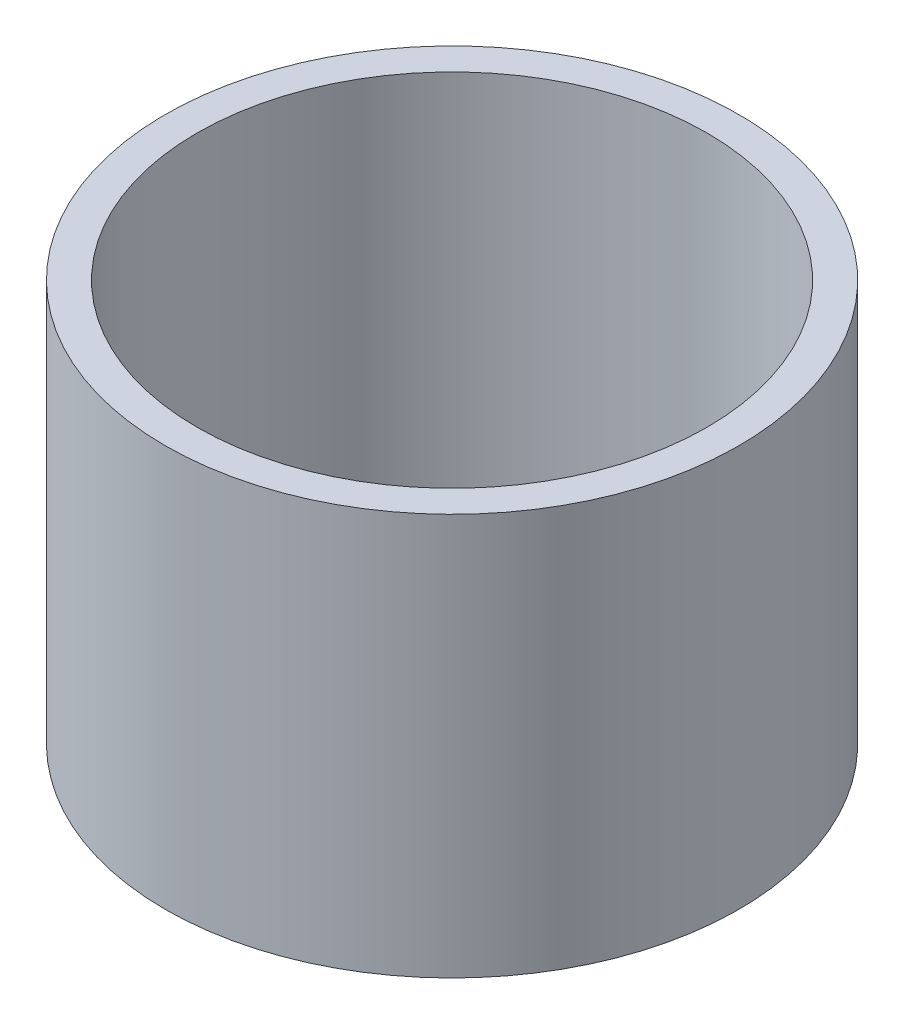
from build123d import *

# Parameters (mm, degrees)
SKETCH1_R           = 9
SKETCH1_R_2         = 8
BOSS_EXTRUDE1_DEPTH = 12.6


with BuildPart() as part:
    # Sketch1 → Boss-Extrude1 (new body)
    with BuildSketch(Plane(origin=(0, 0, 0), x_dir=(1, 0, 0), z_dir=(0, 1, 0))):
        Circle(SKETCH1_R)
        Circle(SKETCH1_R_2, mode=Mode.SUBTRACT)
    extrude(amount=BOSS_EXTRUDE1_DEPTH)


solid = part.part
